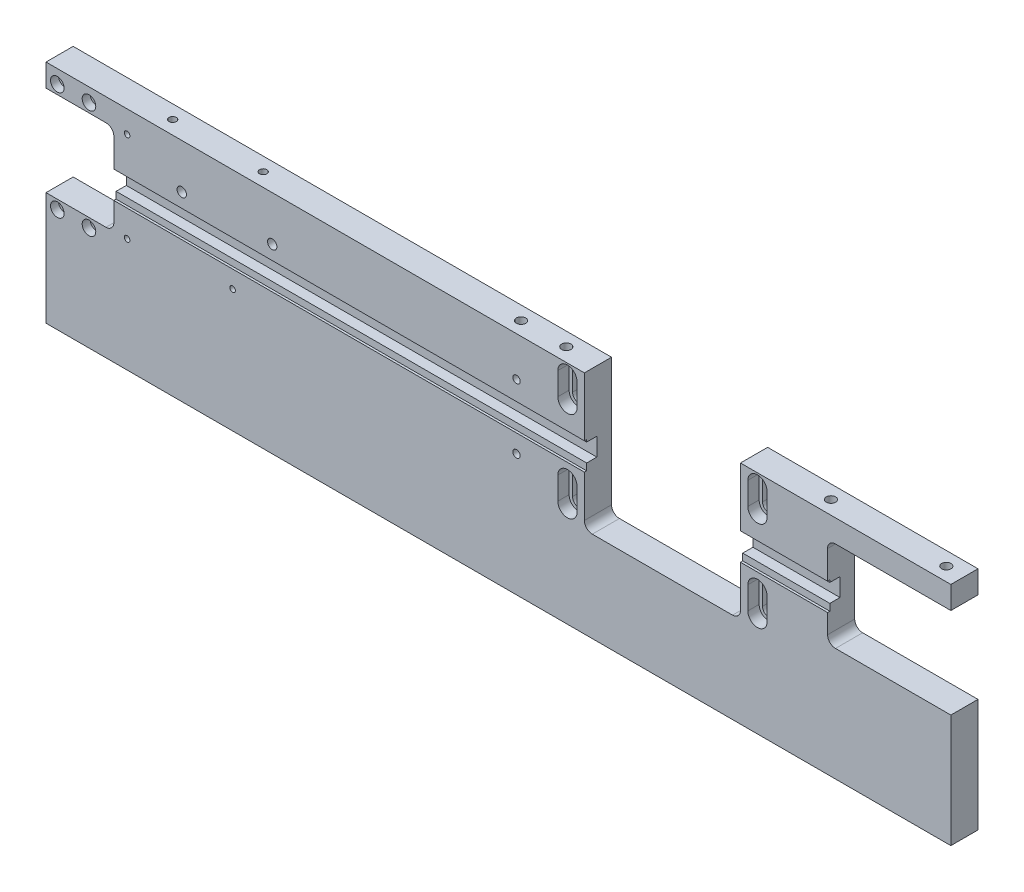
from build123d import *

# Parameters (mm, degrees)
SKETCH1_W                    = 400
SKETCH1_H                    = 100
BASE_DEPTH                   = 12
PART_TAPE_MOVER_CUTOUT_DEPTH = 13
PRESS_PLATE_CUTOUT_DEPTH     = 13
ROLLER_CUTOUT_DEPTH          = 13
SKETCH5_W                    = 315.5
SKETCH5_H                    = 8
PART_TAPE_CUTOUT_DEPTH       = 5.5
SKETCH6_W                    = 315.5
SKETCH6_H                    = 12
CUT_EXTRUDE5_DEPTH           = 1
SKETCH9_R                    = 2.065
CUT_EXTRUDE8_DEPTH           = 10
CUT_EXTRUDE9_DEPTH           = 5
CUT_EXTRUDE10_DEPTH          = 8
LPATTERN1_COUNT              = 2
LPATTERN1_PITCH              = 84
LPATTERN1_COUNT_DIR2         = 2
LPATTERN1_PITCH_DIR2         = 40
SKETCH13_R                   = 3
CUT_EXTRUDE11_DEPTH          = 3.5
SKETCH14_R                   = 1.5
CUT_EXTRUDE12_DEPTH          = 9.5
LPATTERN2_COUNT              = 2
LPATTERN2_PITCH              = 48
SKETCH15_R                   = 1.23
CUT_EXTRUDE13_DEPTH          = 13
SKETCH16_R                   = 2.065
CUT_EXTRUDE14_DEPTH          = 13
SKETCH18_R                   = 1.62
CUT_EXTRUDE15_DEPTH          = 13
SKETCH19_R                   = 2.065
SKETCH19_R_2                 = 1.62
CUT_EXTRUDE16_DEPTH          = 8


with BuildPart() as part:
    # Sketch1 → Base (new body)
    with BuildSketch(Plane.XY):
        Rectangle(SKETCH1_W, SKETCH1_H)
    extrude(amount=BASE_DEPTH)

    # Sketch2 → Part Tape Mover Cutout (cut, through all)
    with BuildSketch(Plane.XY.offset(12)):
        with BuildLine():
            Line((200, 0), (149, 0))
            ThreePointArc((149, 0), (146.525126266, 1.025126266), (145.5, 3.5))
            Line((145.5, 3.5), (145.5, 36.5))
            ThreePointArc((145.5, 36.5), (146.525126266, 38.974873734), (149, 40))
            Line((149, 40), (200, 40))
            Line((200, 40), (200, 0))
        make_face()
    extrude(amount=-PART_TAPE_MOVER_CUTOUT_DEPTH, mode=Mode.SUBTRACT)

    # Sketch3 → Press Plate Cutout (cut, through all)
    with BuildSketch(Plane.XY.offset(12)):
        with BuildLine():
            Line((41.5, -10), (103.5, -10))
            ThreePointArc((103.5, -10), (105.974873734, -8.974873734), (107, -6.5))
            Line((107, -6.5), (107, 50))
            Line((107, 50), (38, 50))
            Line((38, 50), (38, -6.5))
            ThreePointArc((38, -6.5), (39.025126266, -8.974873734), (41.5, -10))
        make_face()
    extrude(amount=-PRESS_PLATE_CUTOUT_DEPTH, mode=Mode.SUBTRACT)

    # Sketch4 → Roller Cutout (cut, through all)
    with BuildSketch(Plane.XY.offset(12)):
        with BuildLine():
            Line((-200, 40), (-173.5, 40))
            ThreePointArc((-173.5, 40), (-171.025126266, 38.974873734), (-170, 36.5))
            Line((-170, 36.5), (-170, 3.5))
            ThreePointArc((-170, 3.5), (-171.025126266, 1.025126266), (-173.5, 0))
            Line((-173.5, 0), (-200, 0))
            Line((-200, 0), (-200, 40))
        make_face()
    extrude(amount=-ROLLER_CUTOUT_DEPTH, mode=Mode.SUBTRACT)

    # Sketch5 → Part Tape Cutout (cut)
    with BuildSketch(Plane.XY.offset(12)):
        with Locations((-12.25, 19)):
            Rectangle(SKETCH5_W, SKETCH5_H)
    extrude(amount=-PART_TAPE_CUTOUT_DEPTH, mode=Mode.SUBTRACT)

    # Sketch6 → Cut-Extrude5 (cut)
    with BuildSketch(Plane.XY.offset(12)):
        with Locations((-12.25, 18)):
            Rectangle(SKETCH6_W, SKETCH6_H)
    extrude(amount=-CUT_EXTRUDE5_DEPTH, mode=Mode.SUBTRACT)

    # Sketch9 → Cut-Extrude8 (cut)
    with BuildSketch(Plane(origin=(0, 50, 0), x_dir=(1, 0, 0), z_dir=(0, 1, 0))):
        with Locations((141, -6)):
            Circle(SKETCH9_R)
        with Locations((192, -6)):
            Circle(SKETCH9_R)
    extrude(amount=-CUT_EXTRUDE8_DEPTH, mode=Mode.SUBTRACT)

    # Sketch11 → Cut-Extrude9 (cut)
    with BuildSketch(Plane.XY.offset(12)):
        with BuildLine():
            Line((110.25, 35), (110.25, 45))
            ThreePointArc((110.25, 45), (114.5, 49.25), (118.75, 45))
            Line((118.75, 45), (118.75, 35))
            ThreePointArc((118.75, 35), (114.5, 30.75), (110.25, 35))
        make_face()
    cut_extrude9 = extrude(amount=-CUT_EXTRUDE9_DEPTH, mode=Mode.SUBTRACT)

    # Sketch12 → Cut-Extrude10 (cut, through all)
    with BuildSketch(Plane.XY.offset(7)):
        with BuildLine():
            Line((117.25, 35), (117.25, 45))
            ThreePointArc((117.25, 45), (114.5, 47.75), (111.75, 45))
            Line((111.75, 45), (111.75, 35))
            ThreePointArc((111.75, 35), (114.5, 32.25), (117.25, 35))
        make_face()
    cut_extrude10 = extrude(amount=-CUT_EXTRUDE10_DEPTH, mode=Mode.SUBTRACT)

    # LPattern1: Cut-Extrude9, Cut-Extrude10 2 × 2
    with Locations(*[(-i * LPATTERN1_PITCH, -j * LPATTERN1_PITCH_DIR2, 0) for i in range(LPATTERN1_COUNT) for j in range(LPATTERN1_COUNT_DIR2) if (i, j) != (0, 0)]):
        add(cut_extrude9, mode=Mode.SUBTRACT)
        add(cut_extrude10, mode=Mode.SUBTRACT)

    # Sketch13 → Cut-Extrude11 (cut)
    with BuildSketch(Plane.XY.offset(12)):
        with Locations((-181, 44)):
            Circle(SKETCH13_R)
        with Locations((-195, 44)):
            Circle(SKETCH13_R)
    cut_extrude11 = extrude(amount=-CUT_EXTRUDE11_DEPTH, mode=Mode.SUBTRACT)

    # Sketch14 → Cut-Extrude12 (cut, through all)
    with BuildSketch(Plane.XY.offset(8.5)):
        with Locations((-181, 44)):
            Circle(SKETCH14_R)
        with Locations((-195, 44)):
            Circle(SKETCH14_R)
    cut_extrude12 = extrude(amount=-CUT_EXTRUDE12_DEPTH, mode=Mode.SUBTRACT)

    # LPattern2: Cut-Extrude11, Cut-Extrude12 ×2
    with Locations(*[(0, -i * LPATTERN2_PITCH, 0) for i in range(1, LPATTERN2_COUNT)]):
        add(cut_extrude11, mode=Mode.SUBTRACT)
        add(cut_extrude12, mode=Mode.SUBTRACT)

    # Sketch15 → Cut-Extrude13 (cut, through all)
    with BuildSketch(Plane.XY.offset(12)):
        with Locations((-164.15, 40.25)):
            Circle(SKETCH15_R)
        with Locations((-164.15, 0.25)):
            Circle(SKETCH15_R)
        with Locations((-117.5, 4.3)):
            Circle(SKETCH15_R)
    extrude(amount=-CUT_EXTRUDE13_DEPTH, mode=Mode.SUBTRACT)

    # Sketch16 → Cut-Extrude14 (cut, through all)
    with BuildSketch(Plane.XY.offset(12)):
        with Locations((-140, 30.25)):
            Circle(SKETCH16_R)
        with Locations((-100, 30.25)):
            Circle(SKETCH16_R)
    extrude(amount=-CUT_EXTRUDE14_DEPTH, mode=Mode.SUBTRACT)

    # Sketch18 → Cut-Extrude15 (cut, through all)
    with BuildSketch(Plane.XY.offset(12)):
        with Locations((8, 32.5)):
            Circle(SKETCH18_R)
        with Locations((8, 4)):
            Circle(SKETCH18_R)
    extrude(amount=-CUT_EXTRUDE15_DEPTH, mode=Mode.SUBTRACT)

    # Sketch19 → Cut-Extrude16 (cut)
    with BuildSketch(Plane(origin=(0, 50, 0), x_dir=(1, 0, 0), z_dir=(0, 1, 0))):
        with Locations((24, -6)):
            Circle(SKETCH19_R)
        with Locations((4, -6)):
            Circle(SKETCH19_R)
        with Locations((-110, -6)):
            Circle(SKETCH19_R_2)
        with Locations((-150, -6)):
            Circle(SKETCH19_R_2)
    extrude(amount=-CUT_EXTRUDE16_DEPTH, mode=Mode.SUBTRACT)


solid = part.part
